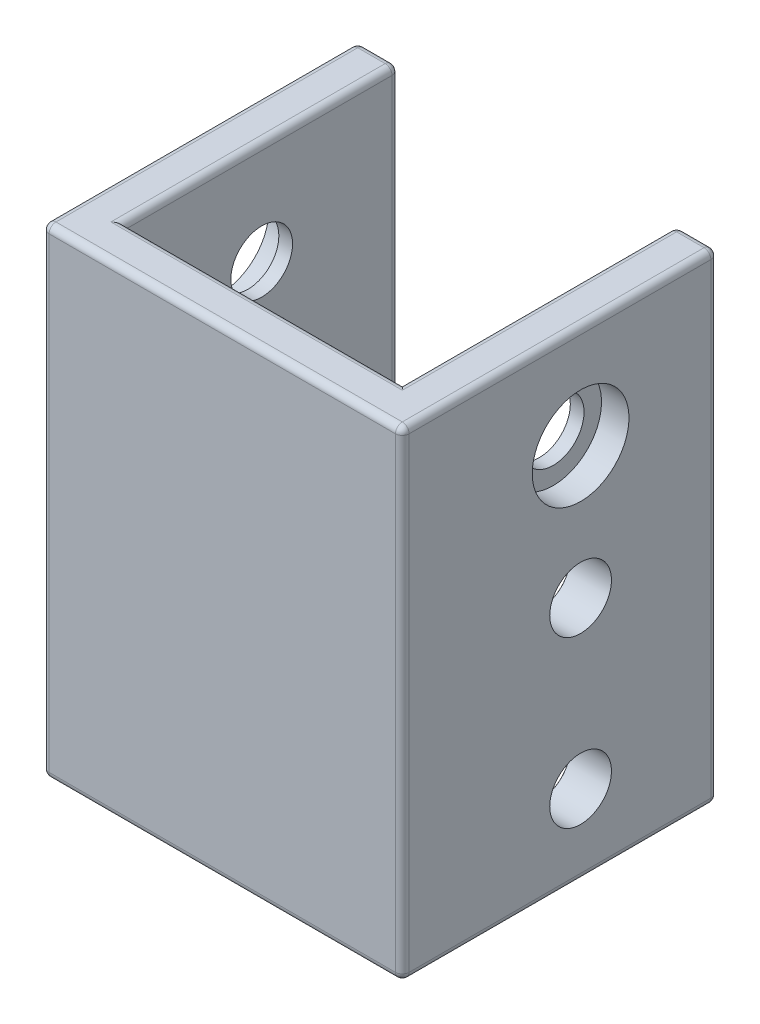
from build123d import *

# Parameters (mm, degrees)
BOSS_EXTRUDE1_DEPTH           = 70
SKETCH8_R                     = 4.5
CUT_EXTRUDE4_DEPTH            = 53.5
SKETCH10_R                    = 7.05
CUT_EXTRUDE5_DEPTH            = 4
FILLET13_R                    = 1
M8_CLEARANCE_HOLE1_AT_2_COUNT = 2
M8_CLEARANCE_HOLE1_AT_2_PITCH = 24.109474775


with BuildPart() as part:
    # Sketch1 → Boss-Extrude1 (new body)
    with BuildSketch(Plane(origin=(0, 0, 0), x_dir=(1, 0, 0), z_dir=(0, 1, 0))):
        Polygon((-26.25, -26.25), (26.25, -26.25), (26.25, 19.75), (20.25, 19.75), (20.25, -20.25), (-20.25, -20.25), (-20.25, 19.75), (-26.25, 19.75), align=None)
    extrude(amount=BOSS_EXTRUDE1_DEPTH)

    # Sketch8 → Cut-Extrude4 (cut, through all)
    with BuildSketch(Plane(origin=(26.25, 0, 0), x_dir=(0, 0, -1), z_dir=(1, 0, 0))):
        with Locations((-0.25, 55)):
            Circle(SKETCH8_R)
    extrude(amount=-CUT_EXTRUDE4_DEPTH, mode=Mode.SUBTRACT)

    # Sketch10 → Cut-Extrude5 (cut)
    with BuildSketch(Plane.ZY.offset(26.25)):
        with Locations((0.25, 55)):
            Circle(SKETCH10_R)
    cut_extrude5 = extrude(amount=-CUT_EXTRUDE5_DEPTH, mode=Mode.SUBTRACT)

    # Mirror1: Cut-Extrude5 across plane
    add(cut_extrude5.mirror(Plane(origin=(0, 0, 0), x_dir=(0, 0, 1), z_dir=(1, 0, 0))), mode=Mode.SUBTRACT)

    # Fillet13
    fillet13_edges = [part.edges().sort_by_distance(p)[0] for p in [
        (26.25, 0, 3.25),
        (0, 0, 26.25),
        (0, 70, 20.25),
        (-26.25, 0, 3.25),
        (-23.25, 0, -19.75),
        (-20.25, 0, 0.25),
        (0, 0, 20.25),
        (20.25, 0, 0.25),
        (-20.25, 70, 0.25),
        (20.25, 35, -19.75),
        (26.25, 35, -19.75),
        (26.25, 35, 26.25),
        (-26.25, 35, 26.25),
        (-26.25, 35, -19.75),
        (-20.25, 35, -19.75),
        (-23.25, 70, -19.75),
        (-26.25, 70, 3.25),
        (0, 70, 26.25),
        (26.25, 70, 3.25),
        (23.25, 70, -19.75),
        (20.25, 70, 0.25),
        (23.25, 0, -19.75),
    ]]
    fillet(fillet13_edges, radius=FILLET13_R)

    # Sketch18 → M8 Clearance Hole1 (revolve, cut)
    with BuildSketch(Plane(origin=(-20.25, 35.786178525, 0.25), x_dir=(0, 0, -1), z_dir=(0, 1, 0))):
        Polygon((0, 0), (0, 15.703872786), (4.5, 13), (4.5, 0.025), (4.525, 0), align=None)
    m8_clearance_hole1 = revolve(axis=Axis((-13.9, 35.786178525, 0.25), (-1, 0, 0)), mode=Mode.SUBTRACT)

    # M8 Clearance Hole1 at 2: M8 Clearance Hole1 ×2
    with Locations(*[(0, -i * M8_CLEARANCE_HOLE1_AT_2_PITCH, 0) for i in range(1, M8_CLEARANCE_HOLE1_AT_2_COUNT)]):
        add(m8_clearance_hole1, mode=Mode.SUBTRACT)

    # Mirror2: M8 Clearance Hole1 across plane
    add(m8_clearance_hole1.mirror(Plane(origin=(0, 0, 0), x_dir=(0, 0, 1), z_dir=(1, 0, 0))), mode=Mode.SUBTRACT)

    # Mirror2 copy 1 sketch → Mirror2 copy 1 (revolve, cut)
    with BuildSketch(Plane(origin=(20.25, 11.676703751, 0.25), x_dir=(0, 0, -1), z_dir=(0, 1, 0))):
        Polygon((0, 0), (0, -15.703872786), (4.5, -13), (4.5, -0.025), (4.525, 0), align=None)
    revolve(axis=Axis((13.9, 11.676703751, 0.25), (-1, 0, 0)), mode=Mode.SUBTRACT)


solid = part.part
